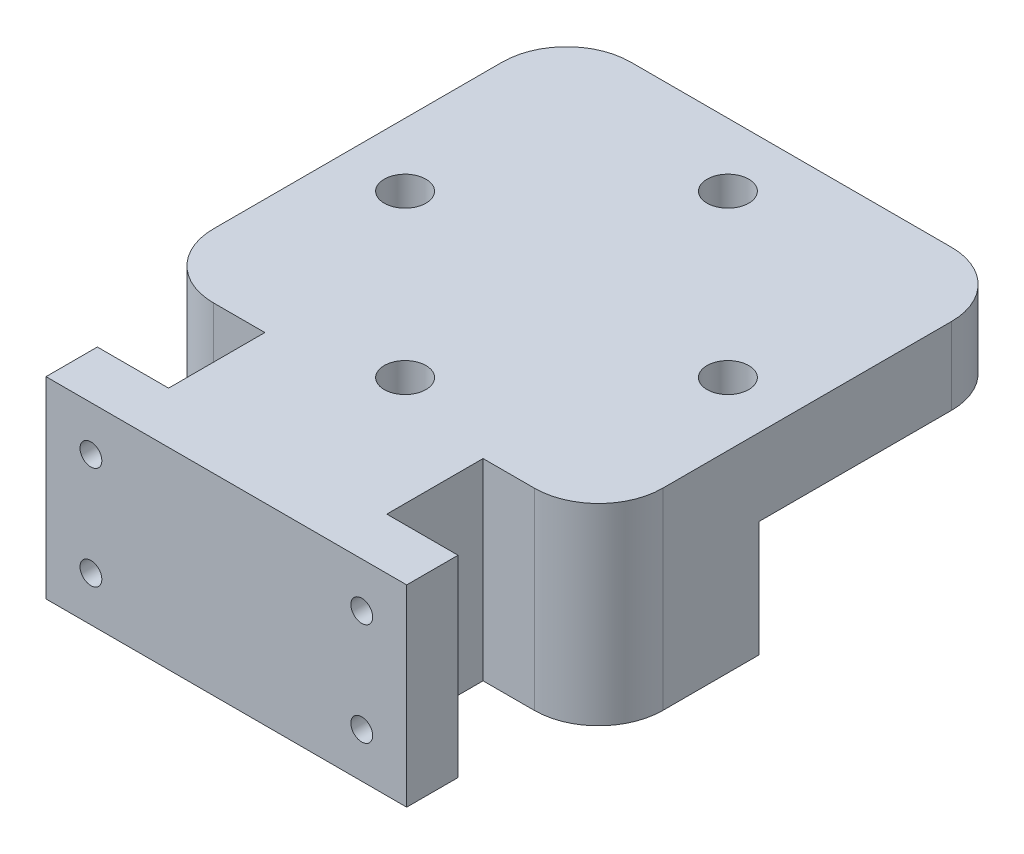
from build123d import *

# Parameters (mm, degrees)
SKETCH1_W                = 56.2
SKETCH1_H                = 30
BOSS_EXTRUDE1_DEPTH      = 5
SKETCH3_W                = 56.2
SKETCH3_H                = 30
BOSS_EXTRUDE2_DEPTH      = 3
SKETCH4_R                = 1.7
CUT_EXTRUDE2_DEPTH       = 8
SKETCH8_R                = 2.6
CUT_EXTRUDE4_DEPTH       = 4
SKETCH9_W                = 15
SKETCH9_H                = 30
BOSS_EXTRUDE5_DEPTH      = 17
BOSS_EXTRUDE5_DEPTH_BACK = 17
BOSS_EXTRUDE6_DEPTH      = 12
SKETCH11_R               = 2.2
CUT_EXTRUDE5_DEPTH       = 12
BOSS_EXTRUDE7_DEPTH      = 18
CUT_EXTRUDE6_DEPTH       = 18
SKETCH14_R               = 3.25
CUT_EXTRUDE7_DEPTH       = 8


with BuildPart() as part:
    # Sketch1 → Boss-Extrude1 (new body)
    with BuildSketch(Plane.XY):
        with Locations((28.1, -15)):
            Rectangle(SKETCH1_W, SKETCH1_H)
    extrude(amount=BOSS_EXTRUDE1_DEPTH)

    # Sketch3 → Boss-Extrude2 (add)
    with BuildSketch(Plane.XY.offset(5)):
        with Locations((28.1, -15)):
            Rectangle(SKETCH3_W, SKETCH3_H)
    extrude(amount=BOSS_EXTRUDE2_DEPTH)

    # Sketch4 → Cut-Extrude2 (cut)
    with BuildSketch(Plane(origin=(0, 0, 0), x_dir=(-1, 0, 0), z_dir=(0, 0, -1))):
        with Locations((-49.2, -7)):
            Circle(SKETCH4_R)
        with Locations((-7, -7)):
            Circle(SKETCH4_R)
        with Locations((-7, -23)):
            Circle(SKETCH4_R)
        with Locations((-49.2, -23)):
            Circle(SKETCH4_R)
    extrude(amount=-CUT_EXTRUDE2_DEPTH, mode=Mode.SUBTRACT)

    # Sketch8 → Cut-Extrude4 (cut)
    with BuildSketch(Plane(origin=(0, 0, 0), x_dir=(-1, 0, 0), z_dir=(0, 0, -1))):
        with Locations((-49.2, -7)):
            Circle(SKETCH8_R)
        with Locations((-7, -7)):
            Circle(SKETCH8_R)
        with Locations((-7, -23)):
            Circle(SKETCH8_R)
        with Locations((-49.2, -23)):
            Circle(SKETCH8_R)
    extrude(amount=-CUT_EXTRUDE4_DEPTH, mode=Mode.SUBTRACT)

    # Sketch9 → Boss-Extrude5 (add, two sides)
    with BuildSketch(Plane(origin=(28.1, 0, 0), x_dir=(0, 0, -1), z_dir=(1, 0, 0))) as boss_extrude5_sk:
        with Locations((7.5, -15)):
            Rectangle(SKETCH9_W, SKETCH9_H)
    extrude(amount=BOSS_EXTRUDE5_DEPTH)
    extrude(boss_extrude5_sk.sketch, amount=-BOSS_EXTRUDE5_DEPTH_BACK)

    # Sketch10 → Boss-Extrude6 (add)
    with BuildSketch(Plane(origin=(0, 0, 0), x_dir=(1, 0, 0), z_dir=(0, 1, 0))):
        with BuildLine():
            Line((53.1, 15), (3.1, 15))
            ThreePointArc((3.1, 15), (-3.971068, 17.928932), (-6.9, 25))
            Line((-6.9, 25), (-6.9, 70))
            ThreePointArc((-6.9, 70), (-3.971068, 77.071068), (3.1, 80))
            Line((3.1, 80), (53.1, 80))
            ThreePointArc((53.1, 80), (60.171068, 77.071068), (63.1, 70))
            Line((63.1, 70), (63.1, 25))
            ThreePointArc((63.1, 25), (60.171068, 17.928932), (53.1, 15))
        make_face()
    extrude(amount=-BOSS_EXTRUDE6_DEPTH)

    # Sketch11 → Cut-Extrude5 (cut)
    with BuildSketch(Plane(origin=(0, 0, 0), x_dir=(1, 0, 0), z_dir=(0, 1, 0))):
        with Locations((28.1, 70.15)):
            Circle(SKETCH11_R)
        with Locations((53.25, 45)):
            Circle(SKETCH11_R)
        with Locations((28.1, 19.85)):
            Circle(SKETCH11_R)
        with Locations((2.95, 45)):
            Circle(SKETCH11_R)
    extrude(amount=-CUT_EXTRUDE5_DEPTH, mode=Mode.SUBTRACT)

    # Sketch12 → Boss-Extrude7 (add)
    with BuildSketch(Plane(origin=(0, -12, 0), x_dir=(1, 0, 0), z_dir=(0, 1, 0))):
        with BuildLine():
            Line((45.1, 13), (11.1, 13))
            Line((11.1, 13), (11.1, 15))
            Line((11.1, 15), (3.1, 15))
            ThreePointArc((3.1, 15), (-3.971068, 17.928932), (-6.9, 25))
            Line((-6.9, 25), (-6.9, 40))
            Line((-6.9, 40), (-2.494117, 40))
            ThreePointArc((-2.494117, 40), (28.1, 14), (58.694117, 40))
            Line((58.694117, 40), (63.1, 40))
            Line((63.1, 40), (63.1, 25))
            ThreePointArc((63.1, 25), (60.171068, 17.928932), (53.1, 15))
            Line((53.1, 15), (45.1, 15))
            Line((45.1, 15), (45.1, 13))
        make_face()
    extrude(amount=-BOSS_EXTRUDE7_DEPTH)

    # Sketch13 → Cut-Extrude6 (cut)
    with BuildSketch(Plane(origin=(0, -12, 0), x_dir=(1, 0, 0), z_dir=(0, 1, 0))):
        with BuildLine():
            Line((20.28975, 15), (35.91025, 15))
            ThreePointArc((35.91025, 15), (28.1, 14), (20.28975, 15))
        make_face()
    extrude(amount=-CUT_EXTRUDE6_DEPTH, mode=Mode.SUBTRACT)

    # Sketch14 → Cut-Extrude7 (cut)
    with BuildSketch(Plane(origin=(0, 0, 0), x_dir=(1, 0, 0), z_dir=(0, 1, 0))):
        with Locations((28.1, 70.15)):
            Circle(SKETCH14_R)
        with Locations((53.25, 45)):
            Circle(SKETCH14_R)
        with Locations((28.1, 19.85)):
            Circle(SKETCH14_R)
        with Locations((2.95, 45)):
            Circle(SKETCH14_R)
    extrude(amount=-CUT_EXTRUDE7_DEPTH, mode=Mode.SUBTRACT)


solid = part.part
